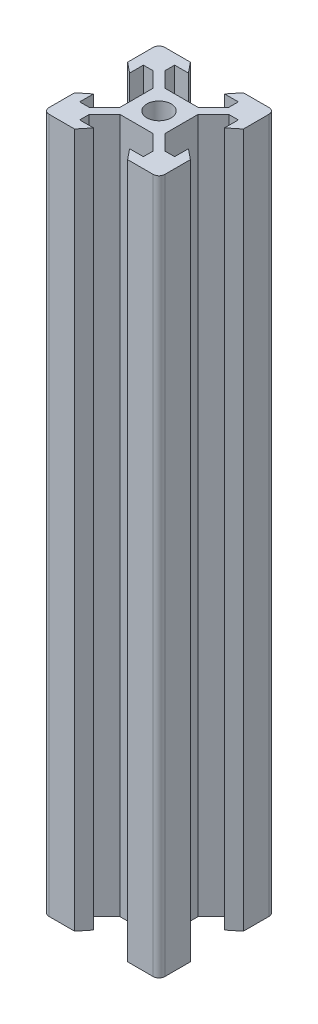
from build123d import *

# Parameters (mm, degrees)
SKETCH1_R           = 2.1
BOSS_EXTRUDE1_DEPTH = 120


with BuildPart() as part:
    # Sketch1 → Boss-Extrude1 (new body)
    with BuildSketch(Plane(origin=(0, 0, 0), x_dir=(1, 0, 0), z_dir=(0, 1, 0))):
        with BuildLine():
            Line((-5.5, 8.2), (-3.125, 8.2))
            Line((-3.125, 8.2), (-4.58, 10))
            Line((-4.58, 10), (-9, 10))
            ThreePointArc((-9, 10), (-9.707106781, 9.707106781), (-10, 9))
            Line((-10, 9), (-10, 4.58))
            Line((-10, 4.58), (-8.2, 3.125))
            Line((-8.2, 3.125), (-8.2, 5.5))
            Line((-8.2, 5.5), (-6.56, 5.5))
            Line((-6.56, 5.5), (-3.9, 2.84))
            Line((-3.9, 2.84), (-3.9, -2.84))
            Line((-3.9, -2.84), (-6.56, -5.5))
            Line((-6.56, -5.5), (-8.2, -5.5))
            Line((-8.2, -5.5), (-8.2, -3.125))
            Line((-8.2, -3.125), (-10, -4.58))
            Line((-10, -4.58), (-10, -9))
            ThreePointArc((-10, -9), (-9.707106781, -9.707106781), (-9, -10))
            Line((-9, -10), (-4.58, -10))
            Line((-4.58, -10), (-3.125, -8.2))
            Line((-3.125, -8.2), (-5.5, -8.2))
            Line((-5.5, -8.2), (-5.5, -6.56))
            Line((-5.5, -6.56), (-2.84, -3.9))
            Line((-2.84, -3.9), (2.84, -3.9))
            Line((2.84, -3.9), (5.5, -6.56))
            Line((5.5, -6.56), (5.5, -8.2))
            Line((5.5, -8.2), (3.125, -8.2))
            Line((3.125, -8.2), (4.58, -10))
            Line((4.58, -10), (9, -10))
            ThreePointArc((9, -10), (9.707106781, -9.707106781), (10, -9))
            Line((10, -9), (10, -4.58))
            Line((10, -4.58), (8.2, -3.125))
            Line((8.2, -3.125), (8.2, -5.5))
            Line((8.2, -5.5), (6.56, -5.5))
            Line((6.56, -5.5), (3.9, -2.84))
            Line((3.9, -2.84), (3.9, 2.84))
            Line((3.9, 2.84), (6.56, 5.5))
            Line((6.56, 5.5), (8.2, 5.5))
            Line((8.2, 5.5), (8.2, 3.125))
            Line((8.2, 3.125), (10, 4.58))
            Line((10, 4.58), (10, 9))
            ThreePointArc((10, 9), (9.707106781, 9.707106781), (9, 10))
            Line((9, 10), (4.58, 10))
            Line((4.58, 10), (3.125, 8.2))
            Line((3.125, 8.2), (5.5, 8.2))
            Line((5.5, 8.2), (5.5, 6.56))
            Line((5.5, 6.56), (2.84, 3.9))
            Line((2.84, 3.9), (-2.84, 3.9))
            Line((-2.84, 3.9), (-5.5, 6.56))
            Line((-5.5, 6.56), (-5.5, 8.2))
        make_face()
        Circle(SKETCH1_R, mode=Mode.SUBTRACT)
    extrude(amount=BOSS_EXTRUDE1_DEPTH)


solid = part.part
